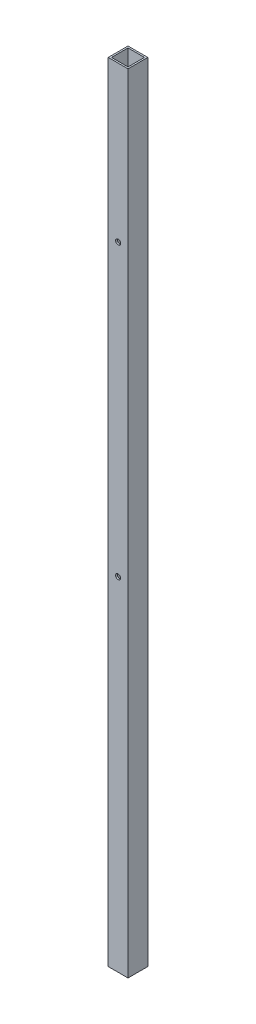
from build123d import *

# Parameters (mm, degrees)
SKETCH1_W           = 19.05
SKETCH1_H           = 19.05
SKETCH1_W_2         = 15.875
SKETCH1_H_2         = 15.875
BOSS_EXTRUDE1_DEPTH = 379.4633
SHELF_HOLES_REACH   = 21.05
SKETCH2_R           = 2.4257
CUT_EXTRUDE1_REACH  = 21.05
SKETCH3_R           = 4.7625


with BuildPart() as part:
    # Sketch1 → Boss-Extrude1 (new body, symmetric)
    with BuildSketch(Plane.ZX):
        Rectangle(SKETCH1_W, SKETCH1_H)
        Rectangle(SKETCH1_W_2, SKETCH1_H_2, mode=Mode.SUBTRACT)
    extrude(amount=BOSS_EXTRUDE1_DEPTH, both=True)

    # Sketch2 → Shelf Holes (cut, up to next)
    with BuildSketch(Plane.XY.offset(9.525), mode=Mode.PRIVATE) as shelf_holes_sk1:
        with Locations((0, -49.2633)):
            Circle(SKETCH2_R)
    shelf_holes_tool1 = extrude(shelf_holes_sk1.sketch, amount=-SHELF_HOLES_REACH, mode=Mode.PRIVATE) & part.part
    add(shelf_holes_tool1.solids().sort_by_distance((0, -49.2633, 9.525))[0], mode=Mode.SUBTRACT)
    # Sketch2 → Shelf Holes (cut, up to next)
    with BuildSketch(Plane.XY.offset(9.525), mode=Mode.PRIVATE) as shelf_holes_sk2:
        with Locations((0, 230.1367)):
            Circle(SKETCH2_R)
    shelf_holes_tool2 = extrude(shelf_holes_sk2.sketch, amount=-SHELF_HOLES_REACH, mode=Mode.PRIVATE) & part.part
    add(shelf_holes_tool2.solids().sort_by_distance((0, 230.1367, 9.525))[0], mode=Mode.SUBTRACT)

    # Sketch3 → Cut-Extrude1 (cut, up to next)
    with BuildSketch(Plane(origin=(0, 0, -9.525), x_dir=(-1, 0, 0), z_dir=(0, 0, -1)), mode=Mode.PRIVATE) as cut_extrude1_sk1:
        with Locations((0, 112.3823)):
            Circle(SKETCH3_R)
    cut_extrude1_tool1 = extrude(cut_extrude1_sk1.sketch, amount=-CUT_EXTRUDE1_REACH, mode=Mode.PRIVATE) & part.part
    add(cut_extrude1_tool1.solids().sort_by_distance((0, 112.3823, -9.525))[0], mode=Mode.SUBTRACT)
    # Sketch3 → Cut-Extrude1 (cut, up to next)
    with BuildSketch(Plane(origin=(0, 0, -9.525), x_dir=(-1, 0, 0), z_dir=(0, 0, -1)), mode=Mode.PRIVATE) as cut_extrude1_sk2:
        with Locations((0, -115.8621)):
            Circle(SKETCH3_R)
    cut_extrude1_tool2 = extrude(cut_extrude1_sk2.sketch, amount=-CUT_EXTRUDE1_REACH, mode=Mode.PRIVATE) & part.part
    add(cut_extrude1_tool2.solids().sort_by_distance((0, -115.8621, -9.525))[0], mode=Mode.SUBTRACT)


solid = part.part
